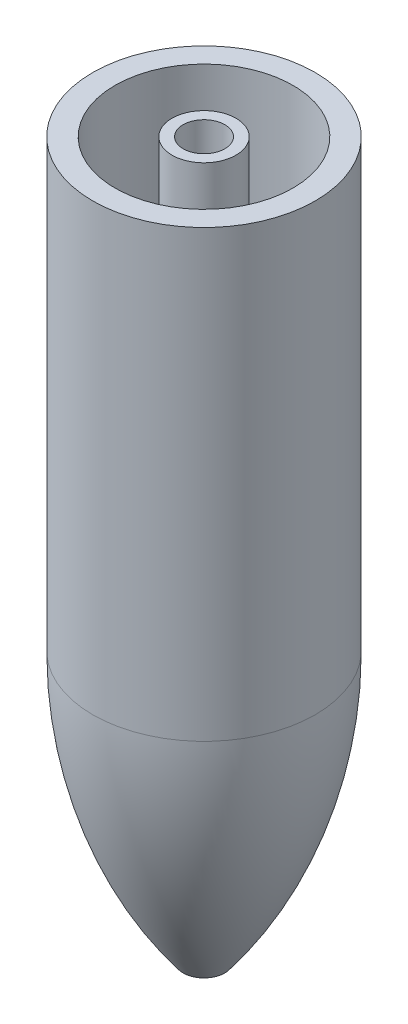
from build123d import *

# Parameters (mm, degrees)
SKETCH2_R          = 2.38125
CUT_EXTRUDE1_DEPTH = 90.050468029
SKETCH5_R          = 10.16
SKETCH5_R_2        = 3.65125
CUT_EXTRUDE4_DEPTH = 50.8


with BuildPart() as part:
    # Sketch1 → Revolve1 (revolve)
    with BuildSketch(Plane.XY):
        with BuildLine():
            Line((0, 0), (0, -50.8))
            ThreePointArc((0, -50.8), (3.280951188, -68.760512242), (12.7, -84.401041651))
            Line((12.7, -84.401041651), (12.7, 0))
            Line((12.7, 0), (0, 0))
        make_face()
    revolve(axis=Axis((12.7, -84.401041651, 0), (0, 1, 0)))

    # Sketch2 → Cut-Extrude1 (cut, through all)
    with BuildSketch(Plane(origin=(0, 0, 0), x_dir=(1, 0, 0), z_dir=(0, 1, 0))):
        with Locations((12.7, 0)):
            Circle(SKETCH2_R)
    extrude(amount=-CUT_EXTRUDE1_DEPTH, mode=Mode.SUBTRACT)

    # Sketch5 → Cut-Extrude4 (cut)
    with BuildSketch(Plane(origin=(0, 0, 0), x_dir=(1, 0, 0), z_dir=(0, 1, 0))):
        with Locations((12.7, 0)):
            Circle(SKETCH5_R)
        with Locations((12.7, 0)):
            Circle(SKETCH5_R_2, mode=Mode.SUBTRACT)
    extrude(amount=-CUT_EXTRUDE4_DEPTH, mode=Mode.SUBTRACT)


solid = part.part
